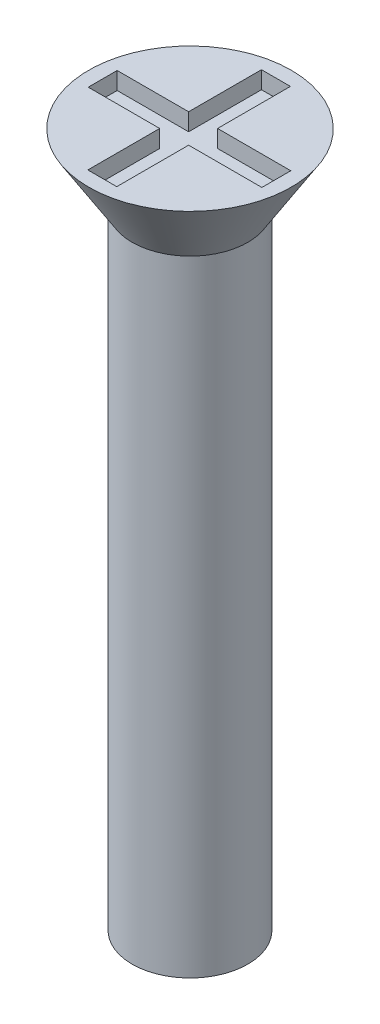
from build123d import *

# Parameters (mm, degrees)
SKETCH1_R           = 1
BOSS_EXTRUDE1_DEPTH = 12
SKETCH2_R           = 1.75
BOSS_EXTRUDE2_DEPTH = 1.3
BOSS_EXTRUDE2_TAPER = 32
SKETCH3_W           = 0.5
SKETCH3_H           = 1.258378485
SKETCH3_H_2         = 1.241621515
SKETCH3_W_2         = 1.234727157
SKETCH3_H_3         = 0.5
SKETCH3_W_3         = 1.265272843
CUT_EXTRUDE1_DEPTH  = 0.3


with BuildPart() as part:
    # Sketch1 → Boss-Extrude1 (new body)
    with BuildSketch(Plane(origin=(0, 0, 0), x_dir=(1, 0, 0), z_dir=(0, 1, 0))):
        Circle(SKETCH1_R)
    extrude(amount=BOSS_EXTRUDE1_DEPTH)

    # Sketch2 → Boss-Extrude2 (add)
    with BuildSketch(Plane(origin=(0, 12, 0), x_dir=(1, 0, 0), z_dir=(0, 1, 0))):
        Circle(SKETCH2_R)
    extrude(amount=-BOSS_EXTRUDE2_DEPTH, taper=BOSS_EXTRUDE2_TAPER)

    # Sketch3 → Cut-Extrude1 (cut)
    with BuildSketch(Plane(origin=(0, 12, 0), x_dir=(1, 0, 0), z_dir=(0, 1, 0))):
        with Locations((-0.015272843, 0.870810758)):
            Rectangle(SKETCH3_W, SKETCH3_H)
        with Locations((-0.015272843, -0.879189242)):
            Rectangle(SKETCH3_W, SKETCH3_H_2)
        with Locations((-0.882636421, -0.008378485)):
            Rectangle(SKETCH3_W_2, SKETCH3_H_3)
        with Locations((0.867363579, -0.008378485)):
            Rectangle(SKETCH3_W_3, SKETCH3_H_3)
        with Locations((-0.015272843, -0.008378485)):
            Rectangle(SKETCH3_W, SKETCH3_H_3)
    extrude(amount=-CUT_EXTRUDE1_DEPTH, mode=Mode.SUBTRACT)


solid = part.part
